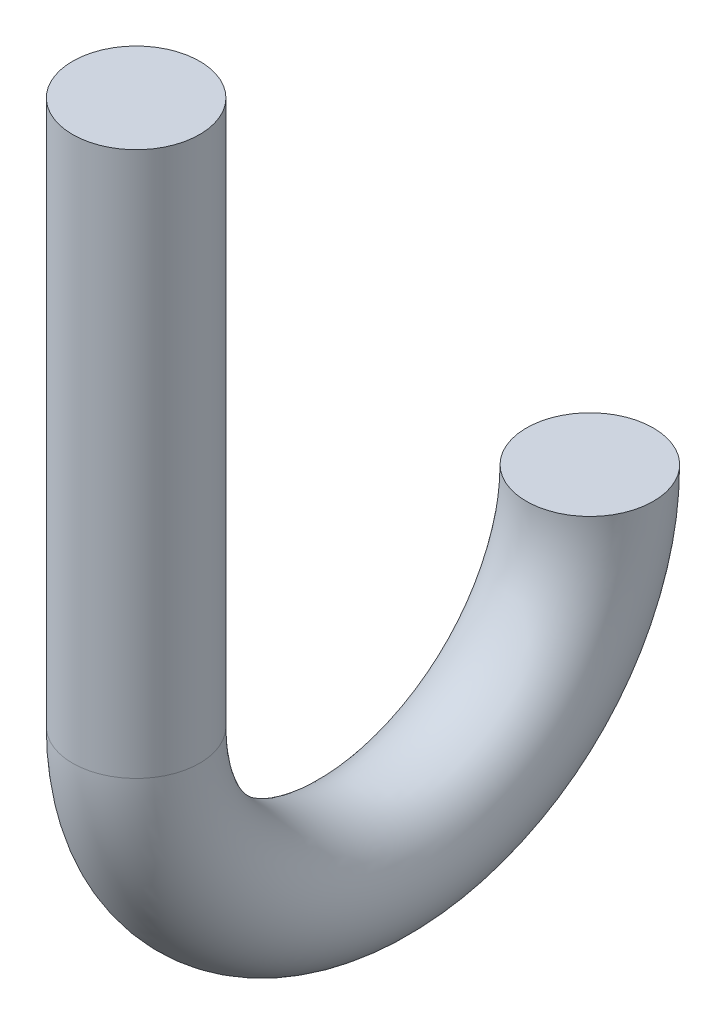
from build123d import *

# Parameters (mm, degrees)
SKETCH3_R = 3.5


with BuildPart() as part:
    # Sweep1: sweep along a path in Sketch2
    with BuildLine(Plane(origin=(0, 0, 0), x_dir=(0, 0, -1), z_dir=(1, 0, 0))) as sweep1_path:
        Line((0, 30), (0, 0))
        ThreePointArc((0, 0), (12.5, -12.5), (25, 0))
    # Sketch3 → Sweep1 (sweep)
    with BuildSketch(Plane(origin=(0, 30, 0), x_dir=(1, 0, 0), z_dir=(0, 1, 0))):
        Circle(SKETCH3_R)
    sweep(path=sweep1_path.line)


solid = part.part
